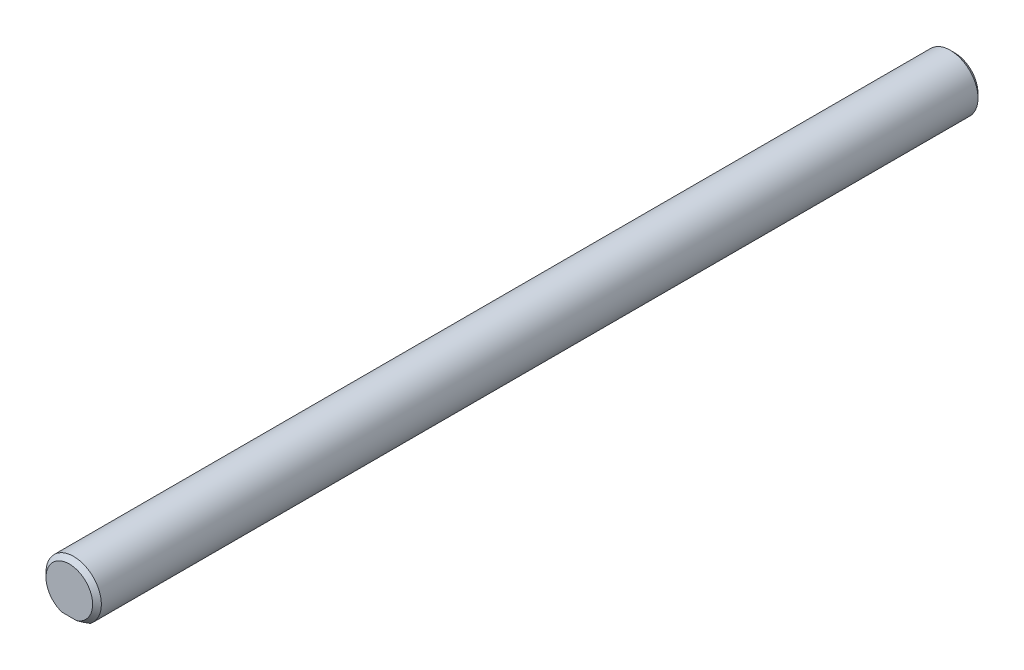
from build123d import *

# Parameters (mm, degrees)
CHAMFER1_SIZE = 0.5


with BuildPart() as part:
    # Sweep1: sweep along a path in Sketch2
    with BuildLine(Plane(origin=(0, 0, 0), x_dir=(1, 0, 0), z_dir=(0, 1, 0))) as sweep1_path:
        Line((0, -50.8), (0, 50.8))
    # Sketch1 → Sweep1 (sweep)
    with BuildSketch(Plane.XY):
        with BuildLine():
            Line((-1.905, -2.54), (1.905, -2.54))
            ThreePointArc((1.905, -2.54), (0, 3.175), (-1.905, -2.54))
        make_face()
    sweep(path=sweep1_path.line)

    # Chamfer1
    chamfer1_edges = [part.edges().sort_by_distance(p)[0] for p in [
        (0, 3.175, -50.8),
        (0, 3.175, 50.8),
    ]]
    chamfer(chamfer1_edges, length=CHAMFER1_SIZE)


solid = part.part
